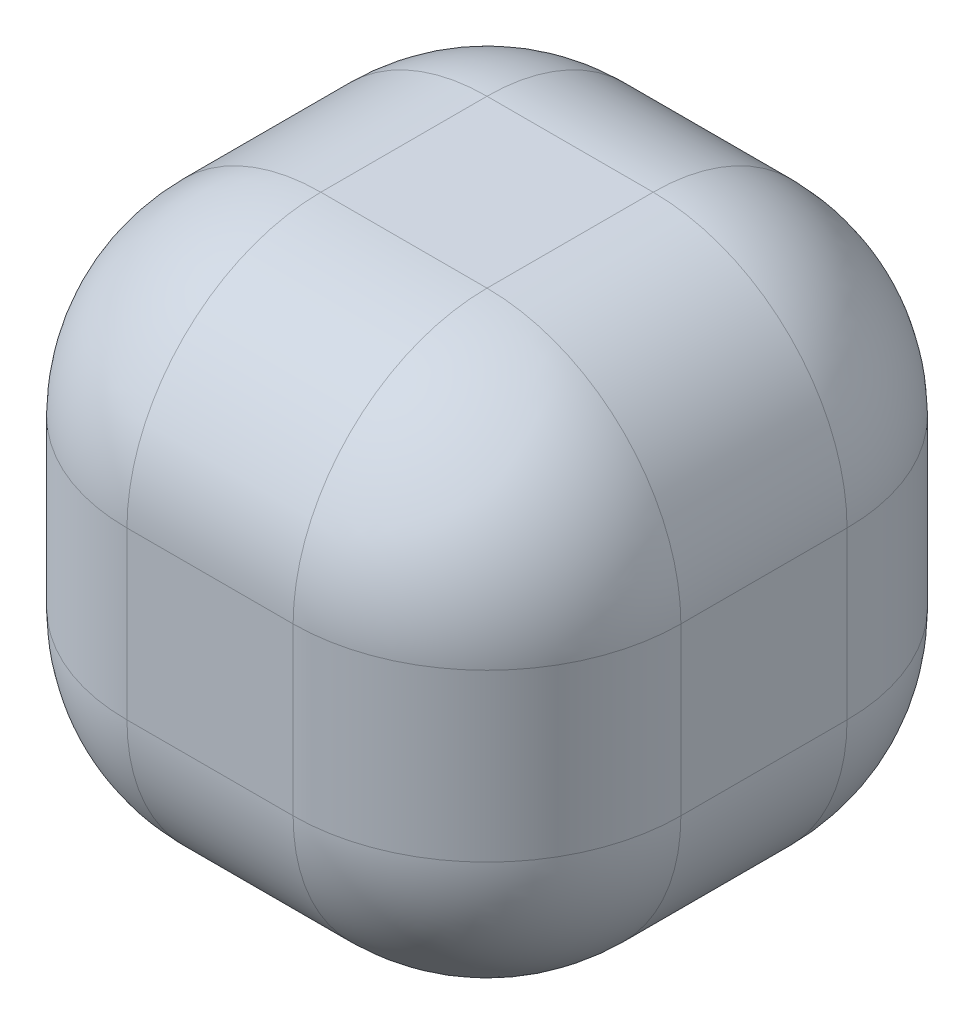
from build123d import *

# Parameters (mm, degrees)
SKETCH1_W           = 40
SKETCH1_H           = 40
BOSS_EXTRUDE1_DEPTH = 40
FILLET1_R           = 14


with BuildPart() as part:
    # Sketch1 → Boss-Extrude1 (new body)
    with BuildSketch(Plane(origin=(0, 0, 0), x_dir=(1, 0, 0), z_dir=(0, 1, 0))):
        Rectangle(SKETCH1_W, SKETCH1_H)
    extrude(amount=BOSS_EXTRUDE1_DEPTH)

    # Fillet1
    fillet1_edges = [part.edges().sort_by_distance(p)[0] for p in [
        (-20, 40, 0),
        (0, 40, 20),
        (20, 40, 0),
        (0, 0, 20),
        (-20, 0, 0),
        (0, 0, -20),
        (20, 0, 0),
        (20, 20, 20),
        (-20, 20, 20),
        (-20, 20, -20),
        (20, 20, -20),
        (0, 40, -20),
    ]]
    fillet(fillet1_edges, radius=FILLET1_R)


solid = part.part
